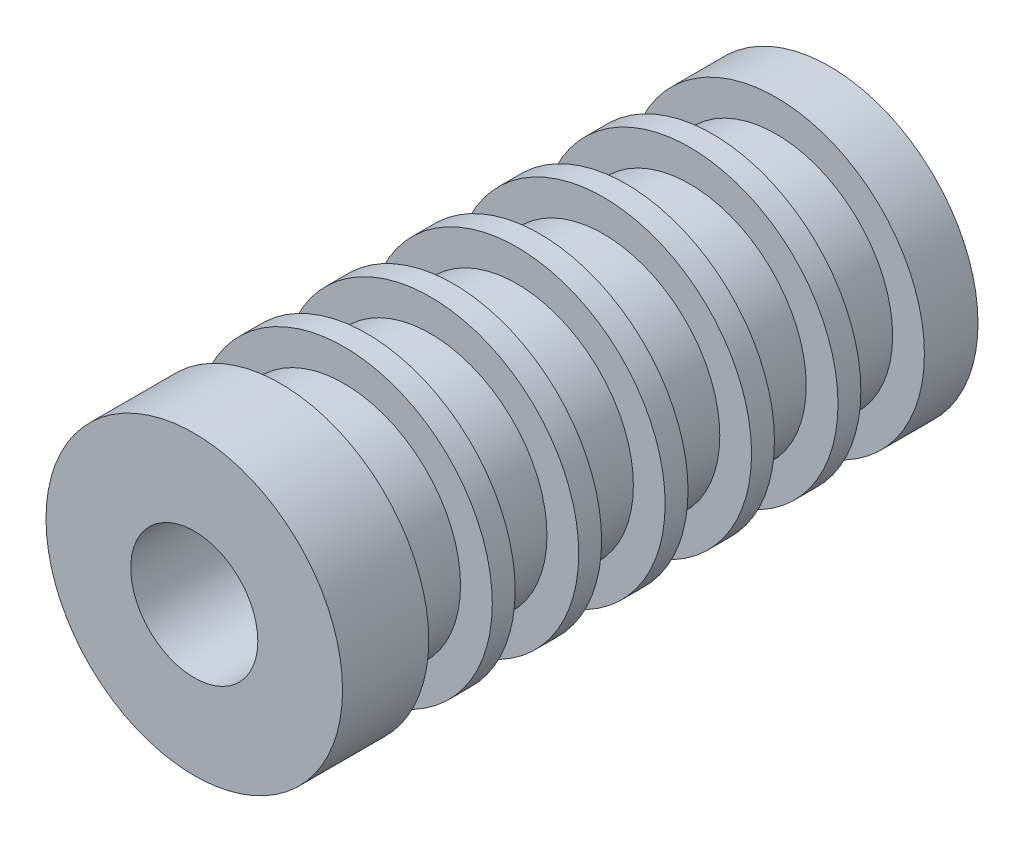
from build123d import *

# Parameters (mm, degrees)
SKETCH1_R          = 11.1125
SKETCH1_R_2        = 3.2004
EXTRUDE1_DEPTH     = 25.4
SKETCH5_R          = 11.1125
SKETCH5_R_2        = 3.2004
CUT_EXTRUDE1_DEPTH = 3.175
SKETCH6_R          = 4.7625
CUT_EXTRUDE2_DEPTH = 48.625
CUT_EXTRUDE3_START = -4.016375
SKETCH7_R          = 11.1125
SKETCH7_R_2        = 8.73125
CUT_EXTRUDE3_DEPTH = 4.7625
LPATTERN1_COUNT    = 6
LPATTERN1_PITCH    = 6.477


with BuildPart() as part:
    # Sketch1 → Extrude1 (new body, symmetric)
    with BuildSketch(Plane.XY):
        Circle(SKETCH1_R)
        Circle(SKETCH1_R_2, mode=Mode.SUBTRACT)
    extrude(amount=EXTRUDE1_DEPTH, both=True)

    # Sketch5 → Cut-Extrude1 (cut)
    with BuildSketch(Plane.XY.offset(25.4)):
        Circle(SKETCH5_R)
        Circle(SKETCH5_R_2, mode=Mode.SUBTRACT)
    extrude(amount=-CUT_EXTRUDE1_DEPTH, mode=Mode.SUBTRACT)

    # Sketch6 → Cut-Extrude2 (cut, through all)
    with BuildSketch(Plane.XY.offset(22.225)):
        Circle(SKETCH6_R)
    extrude(amount=-CUT_EXTRUDE2_DEPTH, mode=Mode.SUBTRACT)

    # Sketch7 → Cut-Extrude3 (cut)
    with BuildSketch(Plane(origin=(0, 0, -25.4), x_dir=(-1, 0, 0), z_dir=(0, 0, -1)).offset(CUT_EXTRUDE3_START)):
        Circle(SKETCH7_R)
        Circle(SKETCH7_R_2, mode=Mode.SUBTRACT)
    cut_extrude3 = extrude(amount=-CUT_EXTRUDE3_DEPTH, mode=Mode.SUBTRACT)

    # LPattern1: Cut-Extrude3 ×6
    with Locations(*[(0, 0, i * LPATTERN1_PITCH) for i in range(1, LPATTERN1_COUNT)]):
        add(cut_extrude3, mode=Mode.SUBTRACT)


solid = part.part
